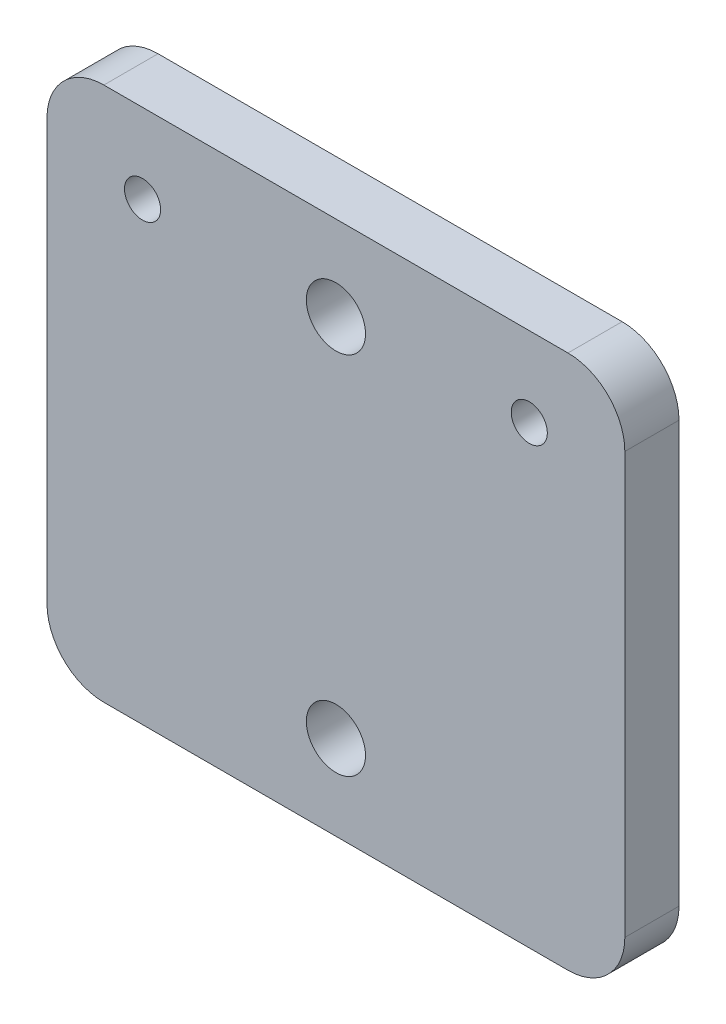
from build123d import *

# Parameters (mm, degrees)
CROQUIS1_W              = 50.8
CROQUIS1_H              = 47
SALIENTE_EXTRUIR1_DEPTH = 4.7625
CROQUIS4_R              = 2.6
CORTAR_EXTRUIR2_DEPTH   = 5.7625
REDONDEO1_R             = 5
CROQUIS7_R              = 1.5875
CORTAR_EXTRUIR5_DEPTH   = 10


with BuildPart() as part:
    # Croquis1 → Saliente-Extruir1 (new body)
    with BuildSketch(Plane.XY):
        with Locations((25.4, 23.5)):
            Rectangle(CROQUIS1_W, CROQUIS1_H)
    extrude(amount=SALIENTE_EXTRUIR1_DEPTH)

    # Croquis4 → Cortar-Extruir2 (cut, through all)
    with BuildSketch(Plane.XY.offset(4.7625)):
        with Locations((25.4, 39.55)):
            Circle(CROQUIS4_R)
        with Locations((25.4, 7.45)):
            Circle(CROQUIS4_R)
    extrude(amount=-CORTAR_EXTRUIR2_DEPTH, mode=Mode.SUBTRACT)

    # Redondeo1
    redondeo1_edges = [part.edges().sort_by_distance(p)[0] for p in [
        (0, 47, 2.38125),
        (50.8, 47, 2.38125),
        (50.8, 0, 2.38125),
        (0, 0, 2.38125),
    ]]
    fillet(redondeo1_edges, radius=REDONDEO1_R)

    # Croquis7 → Cortar-Extruir5 (cut)
    with BuildSketch(Plane.XY.offset(4.7625)):
        with Locations((8.4, 40)):
            Circle(CROQUIS7_R)
        with Locations((42.4, 40)):
            Circle(CROQUIS7_R)
    extrude(amount=-CORTAR_EXTRUIR5_DEPTH, mode=Mode.SUBTRACT)


solid = part.part
